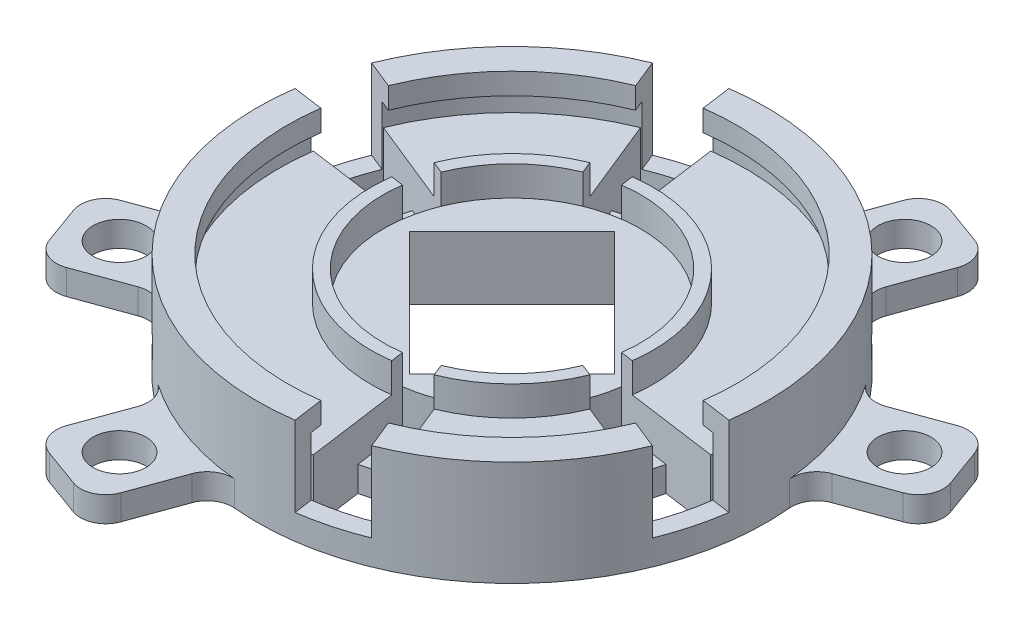
from build123d import *

# Parameters (mm, degrees)
SKETCH4_R                = 1.6
CUT_EXTRUDE1_DEPTH       = 4
CUT_EXTRUDE2_DEPTH       = 2.5
CUT_EXTRUDE3_DEPTH       = 6.84
CUT_EXTRUDE6_DEPTH       = 6.34
CUT_EXTRUDE11_DEPTH      = 3
CIRPATTERN2_COUNT        = 12
SKETCH13_R               = 1.6
CUT_EXTRUDE7_DEPTH       = 4.5
SKETCH14_R               = 1.15
CUT_EXTRUDE10_DEPTH      = 9.36711396
CUT_EXTRUDE10_DEPTH_BACK = 49.76711396
SKETCH15_R               = 2.1
BOSS_EXTRUDE1_DEPTH      = 2
FILLET1_R                = 2


with BuildPart() as part:
    # Sketch1 → Revolve1 (revolve)
    with BuildSketch(Plane.XY):
        Polygon((17.540050021, 3.34), (17.540050021, 1.65), (18.440050021, 1.65), (18.440050021, 0), (18.440050021, -5), (19.940050021, -5), (19.940050021, 3.34), align=None)
    revolve(axis=Axis((-0.259949979, -998.45, 0), (0, 1, 0)))


with BuildPart() as body_2:
    # Sketch1_4 → Revolve3 (revolve)
    with BuildSketch(Plane.XY):
        Polygon((10.940050021, -4), (10.940050021, 0), (10.940050021, 2.35), (9.940050021, 2.35), (9.940050021, 0), (-0.259949979, 0), (-0.259949979, -4), align=None)
        Polygon((18.240050021, -5), (18.240050021, 0), (10.940050021, 0), (10.940050021, -4), (-0.259949979, -4), (-0.259949979, -5), align=None)
    revolve(axis=Axis((-0.259949979, -998.45, 0), (0, 1, 0)))

    # Sketch4 → Cut-Extrude1 (cut)
    with BuildSketch(Plane.XZ.offset(5)):
        with Locations((-7.36637313, -7.742819254)):
            Circle(SKETCH4_R)
        with Locations((7.482869275, 7.106423151)):
            Circle(SKETCH4_R)
    extrude(amount=-CUT_EXTRUDE1_DEPTH, mode=Mode.SUBTRACT)

    # Sketch5 → Cut-Extrude2 (cut)
    with BuildSketch(Plane.XZ.offset(5)):
        Polygon((3.823591682, -13.876970581), (-9.222528431, -0.830850468), (0.570900489, 8.962578452), (13.617020602, -4.083541661), align=None)
    extrude(amount=-CUT_EXTRUDE2_DEPTH, mode=Mode.SUBTRACT)

    # Sketch6 → Cut-Extrude3 (cut, through all)
    with BuildSketch(Plane.XZ.offset(2.5)):
        Polygon((-9.222528431, -0.830850468), (0.570900489, 8.962578452), (8.702628472, 0.830850468), (-1.090800447, -8.962578452), align=None)
    extrude(amount=-CUT_EXTRUDE3_DEPTH, mode=Mode.SUBTRACT)


with BuildPart() as cut_extrude6_tool:
    # Sketch10 → Cut-Extrude6 (new body)
    with BuildSketch(Plane(origin=(0, 3.34, 0), x_dir=(1, 0, 0), z_dir=(0, 1, 0))):
        with BuildLine():
            Line((-3.051509824, 20.006178886), (-1.669549505, 10.102129933))
            ThreePointArc((-1.669549505, 10.102129933), (-2.899904239, 9.852443428), (-4.090265947, 9.453500917))
            Line((-4.090265947, 9.453500917), (-7.845477681, 18.721639071))
            ThreePointArc((-7.845477681, 18.721639071), (-5.48809469, 19.511701691), (-3.051509824, 20.006178886))
        make_face()
    cut_extrude6 = extrude(amount=-CUT_EXTRUDE6_DEPTH)


with BuildPart() as part_1:
    add(part.part)

    # Cut-Extrude6: cut by cut_extrude6_tool
    add(cut_extrude6_tool.part, mode=Mode.SUBTRACT)


with BuildPart() as body_2_1:
    add(body_2.part)

    # Cut-Extrude6: cut by cut_extrude6_tool
    add(cut_extrude6_tool.part, mode=Mode.SUBTRACT)

    # Sketch16 → Cut-Extrude11 (cut, through all)
    with BuildSketch(Plane(origin=(0, -3, 0), x_dir=(1, 0, 0), z_dir=(0, 1, 0))):
        with BuildLine():
            Line((-5.648678817, 13.299778251), (-2.243063037, 14.212310248))
            Line((-2.243063037, 14.212310248), (-2.81657657, 18.322490564))
            ThreePointArc((-2.81657657, 18.322490564), (-5.048102314, 17.869627786), (-7.207091686, 17.146055584))
            Line((-7.207091686, 17.146055584), (-5.648678817, 13.299778251))
        make_face()
    cut_extrude11 = extrude(amount=-CUT_EXTRUDE11_DEPTH, mode=Mode.SUBTRACT)


with BuildPart() as cirpattern2_tool:
    # CirPattern2: Cut-Extrude6, Cut-Extrude11 ×12 about axis, 8 skipped
    cirpattern2_axis = Axis((-0.259949979, -998.45, 0), (0, -1, 0))
    add([cut_extrude6.rotate(cirpattern2_axis, i * 360 / CIRPATTERN2_COUNT) for i in range(1, CIRPATTERN2_COUNT) if i not in (1, 2, 3, 5, 7, 8, 9, 11)])
    add([cut_extrude11.rotate(cirpattern2_axis, i * 360 / CIRPATTERN2_COUNT) for i in range(1, CIRPATTERN2_COUNT) if i not in (1, 2, 3, 5, 7, 8, 9, 11)])


with BuildPart() as part_2:
    add(part_1.part)

    # CirPattern2: cut by cirpattern2_tool
    add(cirpattern2_tool.part, mode=Mode.SUBTRACT)

    # Sketch14 → Cut-Extrude10 (cut, two sides)
    with BuildSketch(Plane(origin=(14.15358199, 0, -14.15358199), x_dir=(-0.707106781, 0, -0.707106781), z_dir=(0.707106781, 0, -0.707106781))) as cut_extrude10_sk:
        with Locations((0.183812393, -2.5)):
            Circle(SKETCH14_R)
    extrude(amount=CUT_EXTRUDE10_DEPTH, mode=Mode.SUBTRACT)
    extrude(cut_extrude10_sk.sketch, amount=-CUT_EXTRUDE10_DEPTH_BACK, mode=Mode.SUBTRACT)

    # Sketch15 → Boss-Extrude1 (add)
    with BuildSketch(Plane.XZ.offset(5)):
        Polygon((16.081029513, -9.778670115), (18.543574545, -3.012883245), (27.188746657, -6.159468564), (24.726201625, -12.925255434), align=None)
        with Locations((22.574580706, -8.311089483)):
            Circle(SKETCH15_R, mode=Mode.SUBTRACT)
        Polygon((12.665305454, -24.986151604), (5.899518585, -27.448696636), (2.752933266, -18.803524525), (9.518720136, -16.340979493), align=None)
        with Locations((8.051139504, -22.834530685)):
            Circle(SKETCH15_R, mode=Mode.SUBTRACT)
        Polygon((-16.600929472, 9.778670115), (-19.063474504, 3.012883245), (-27.708646615, 6.159468564), (-25.246101583, 12.925255434), align=None)
        with Locations((-23.094480664, 8.311089483)):
            Circle(SKETCH15_R, mode=Mode.SUBTRACT)
        Polygon((-13.185205413, 24.986151604), (-6.419418543, 27.448696636), (-3.272833225, 18.803524525), (-10.038620094, 16.340979493), align=None)
        with Locations((-8.571039462, 22.834530685)):
            Circle(SKETCH15_R, mode=Mode.SUBTRACT)
    extrude(amount=-BOSS_EXTRUDE1_DEPTH)

    # Fillet1
    fillet1_edges = [part_2.edges().sort_by_distance(p)[0] for p in [
        (24.726201625, -4, -12.925255434),
        (17.18669011, -4, -10.181097661),
        (19.649235142, -4, -3.415310792),
        (27.188746657, -4, -6.159468564),
        (5.899518585, -4, -27.448696636),
        (9.921147682, -4, -17.446640089),
        (12.665305454, -4, -24.986151604),
        (3.155360813, -4, -19.909185121),
        (-25.246101583, -4, 12.925255434),
        (-17.706590069, -4, 10.181097661),
        (-20.169135101, -4, 3.415310792),
        (-27.708646615, -4, 6.159468564),
        (-6.419418543, -4, 27.448696636),
        (-10.441047641, -4, 17.446640089),
        (-13.185205413, -4, 24.986151604),
        (-3.675260771, -4, 19.909185121),
    ]]
    fillet(fillet1_edges, radius=FILLET1_R)


with BuildPart() as body_2_2:
    add(body_2_1.part)

    # CirPattern2: cut by cirpattern2_tool
    add(cirpattern2_tool.part, mode=Mode.SUBTRACT)

    # Sketch13 → Cut-Extrude7 (cut)
    with BuildSketch(Plane(origin=(14.15358199, 0, -14.15358199), x_dir=(-0.707106781, 0, -0.707106781), z_dir=(0.707106781, 0, -0.707106781))):
        with Locations((0.183812393, -2.5)):
            Circle(SKETCH13_R)
    cut_extrude7 = extrude(amount=-CUT_EXTRUDE7_DEPTH, mode=Mode.SUBTRACT)

    # Mirror1: Cut-Extrude7 across plane
    add(cut_extrude7.mirror(Plane(origin=(-0.12997499, 0, 0.12997499), x_dir=(0.707106781, 0, 0.707106781), z_dir=(-0.707106781, 0, 0.707106781))), mode=Mode.SUBTRACT)


solid = Compound([part_2.part, body_2_2.part])
